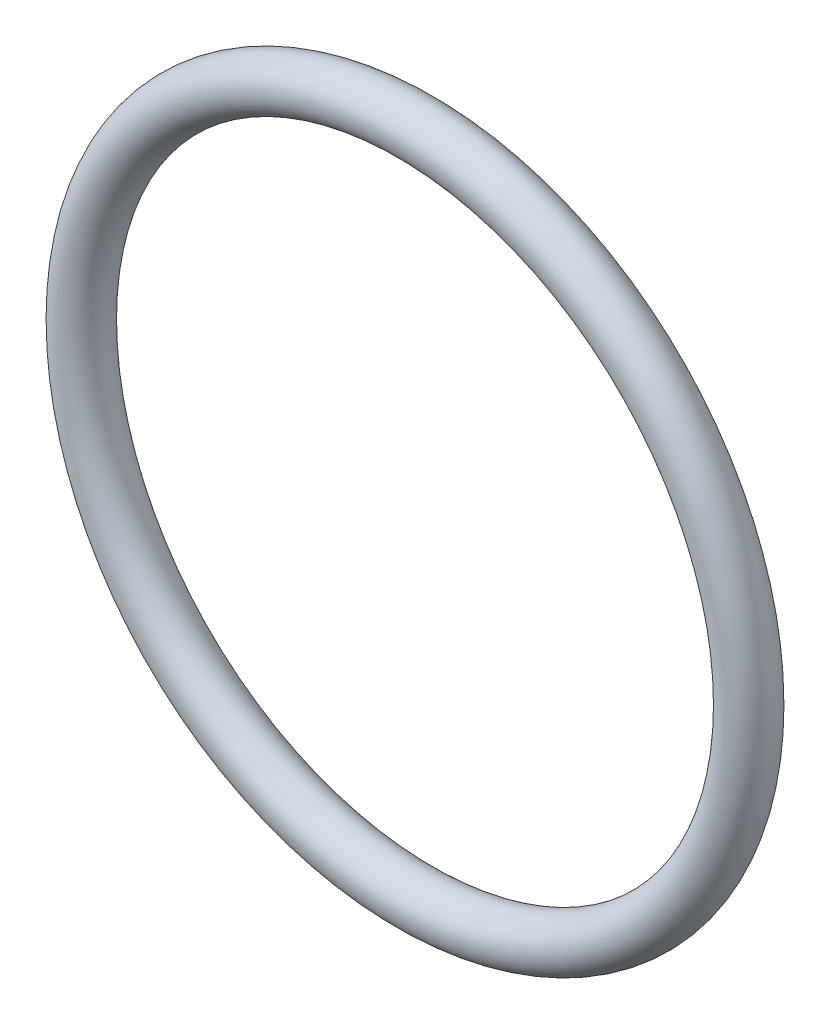
from build123d import *

# Parameters (mm, degrees)
SKETCH2_R = 2.85


with BuildPart() as part:
    # Sweep1: sweep along a path in Sketch1
    with BuildLine(Plane.XY) as sweep1_path:
        CenterArc((0, 0), 35.3, 0, 360)
    # Sketch2 → Sweep1 (sweep)
    with BuildSketch(Plane(origin=(0, 0, 0), x_dir=(1, 0, 0), z_dir=(0, 1, 0))):
        with Locations((-38.15, 0)):
            Circle(SKETCH2_R)
    sweep(path=sweep1_path.line)


solid = part.part
